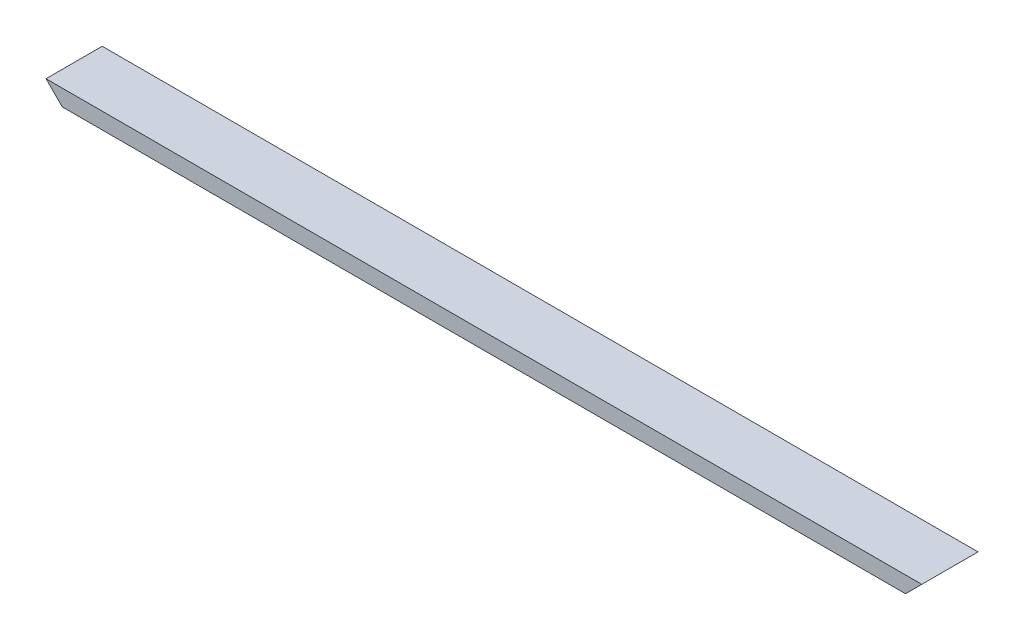
from build123d import *

# Parameters (mm, degrees)
SKETCH1_W               = 38
SKETCH1_H               = 11
SKETCH1_W_2             = 35
SKETCH1_H_2             = 8
BOSS_EXTRUDE1_DEPTH     = 592
CUT_EXTRUDE1_DEPTH      = 1
CUT_EXTRUDE1_DEPTH_BACK = 39
CUT_EXTRUDE3_DEPTH      = 1
CUT_EXTRUDE3_DEPTH_BACK = 39


with BuildPart() as part:
    # Sketch1 → Boss-Extrude1 (new body)
    with BuildSketch(Plane(origin=(0, 0, 0), x_dir=(0, 0, -1), z_dir=(1, 0, 0))):
        Rectangle(SKETCH1_W, SKETCH1_H)
        Rectangle(SKETCH1_W_2, SKETCH1_H_2, mode=Mode.SUBTRACT)
    extrude(amount=BOSS_EXTRUDE1_DEPTH)

    # Sketch2 → Cut-Extrude1 (cut, two sides)
    with BuildSketch(Plane(origin=(0, 0, -19), x_dir=(-1, 0, 0), z_dir=(0, 0, -1))) as cut_extrude1_sk:
        Polygon((844.430011157, 849.930011157), (0, 5.5), (-11, -5.5), (-855.430011157, -849.930011157), (833.430011157, -2538.790033471), (2533.290033471, -838.930011157), align=None)
    extrude(amount=CUT_EXTRUDE1_DEPTH, mode=Mode.SUBTRACT)
    extrude(cut_extrude1_sk.sketch, amount=-CUT_EXTRUDE1_DEPTH_BACK, mode=Mode.SUBTRACT)

    # Sketch3 → Cut-Extrude3 (cut, two sides)
    with BuildSketch(Plane(origin=(0, 0, -19), x_dir=(-1, 0, 0), z_dir=(0, 0, -1))) as cut_extrude3_sk:
        Polygon((-1436.430011157, 849.930011157), (-592, 5.5), (-581, -5.5), (263.430011157, -849.930011157), (-1425.430011157, -2538.790033471), (-3125.290033471, -838.930011157), align=None)
    extrude(amount=CUT_EXTRUDE3_DEPTH, mode=Mode.SUBTRACT)
    extrude(cut_extrude3_sk.sketch, amount=-CUT_EXTRUDE3_DEPTH_BACK, mode=Mode.SUBTRACT)


solid = part.part
